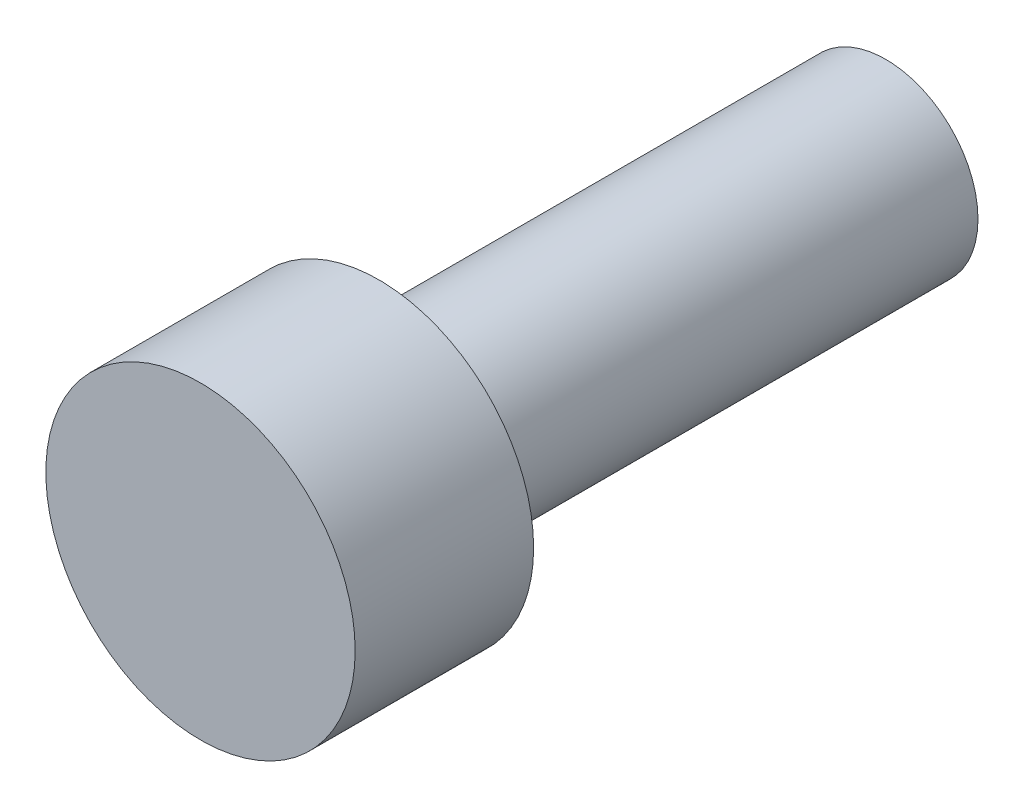
from build123d import *

# Parameters (mm, degrees)
SKETCH1_R           = 6.5
BOSS_EXTRUDE1_DEPTH = 7.5
SKETCH2_R           = 3.875
BOSS_EXTRUDE2_DEPTH = 21.3


with BuildPart() as part:
    # Sketch1 → Boss-Extrude1 (new body)
    with BuildSketch(Plane.XY):
        Circle(SKETCH1_R)
    extrude(amount=BOSS_EXTRUDE1_DEPTH)

    # Sketch2 → Boss-Extrude2 (add)
    with BuildSketch(Plane(origin=(0, 0, 0), x_dir=(-1, 0, 0), z_dir=(0, 0, -1))):
        Circle(SKETCH2_R)
    extrude(amount=BOSS_EXTRUDE2_DEPTH)


solid = part.part
